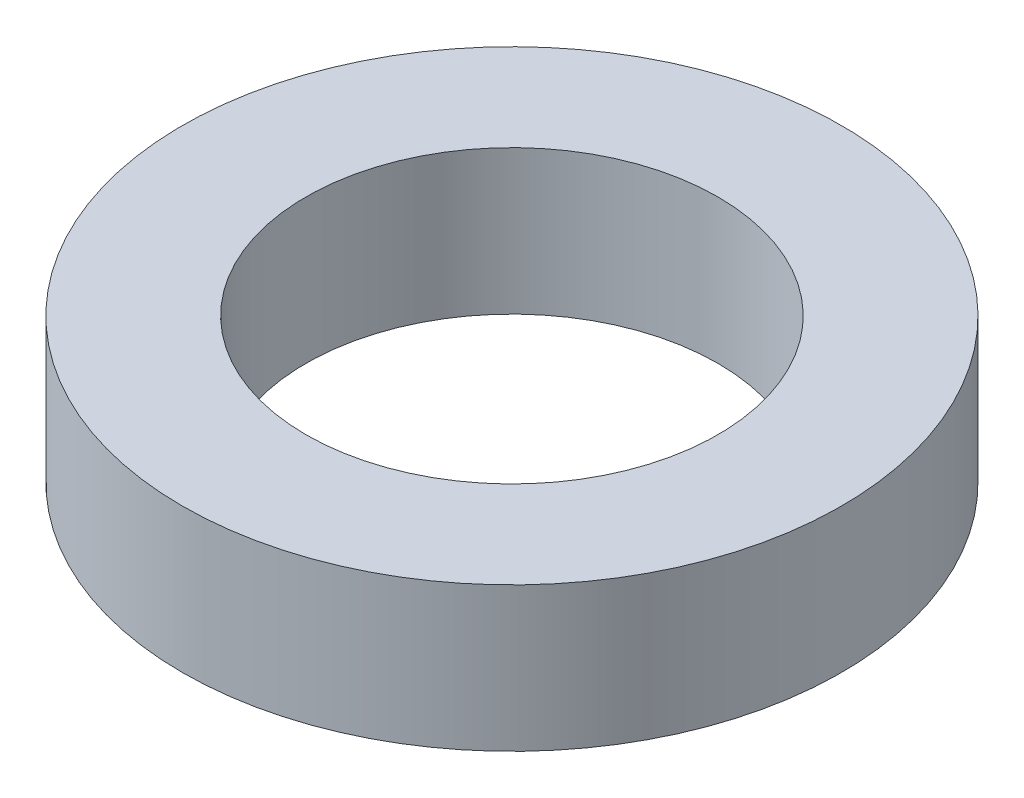
from build123d import *

# Parameters (mm, degrees)
SKETCH1_R           = 16
SKETCH1_R_2         = 10
BOSS_EXTRUDE1_DEPTH = 7


with BuildPart() as part:
    # Sketch1 → Boss-Extrude1 (new body)
    with BuildSketch(Plane(origin=(0, 0, 0), x_dir=(1, 0, 0), z_dir=(0, 1, 0))):
        Circle(SKETCH1_R)
        Circle(SKETCH1_R_2, mode=Mode.SUBTRACT)
    extrude(amount=BOSS_EXTRUDE1_DEPTH)


solid = part.part
